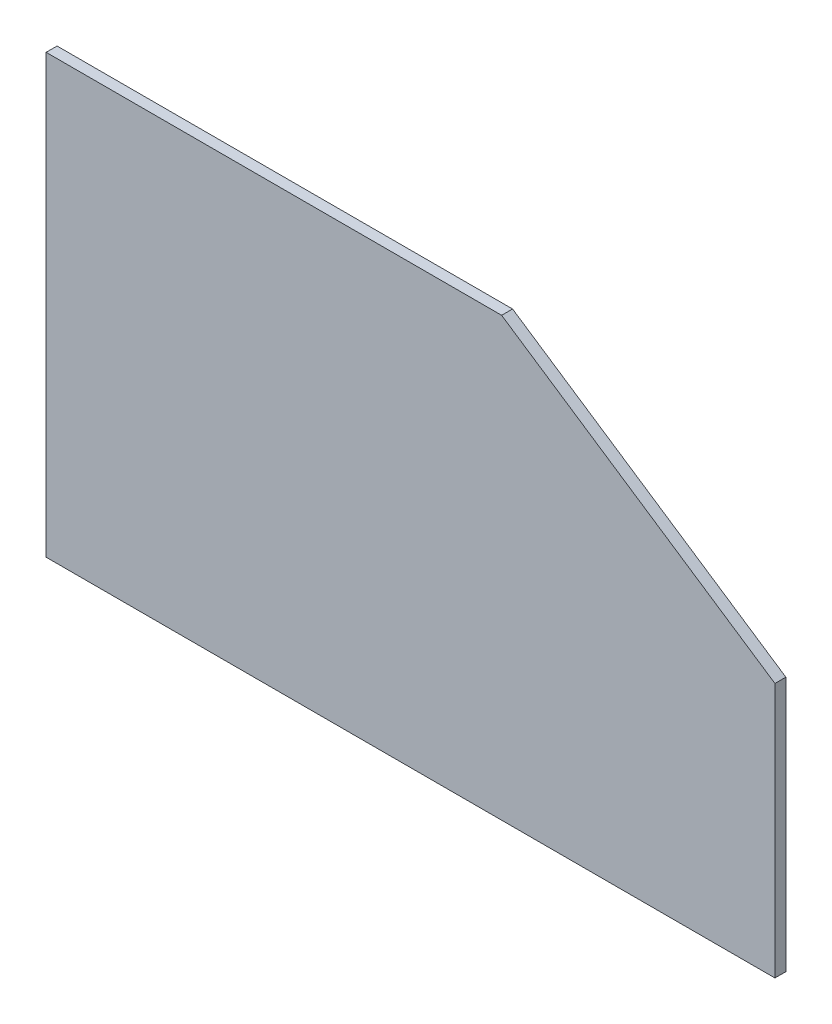
from build123d import *

# Parameters (mm, degrees)
BOSS_EXTRUDE1_DEPTH = 3


with BuildPart() as part:
    # Sketch1 → Boss-Extrude1 (new body)
    with BuildSketch(Plane.XY):
        Polygon((0, 0), (0, 120), (125, 120), (200, 70), (200, 0), align=None)
    extrude(amount=BOSS_EXTRUDE1_DEPTH)


solid = part.part
